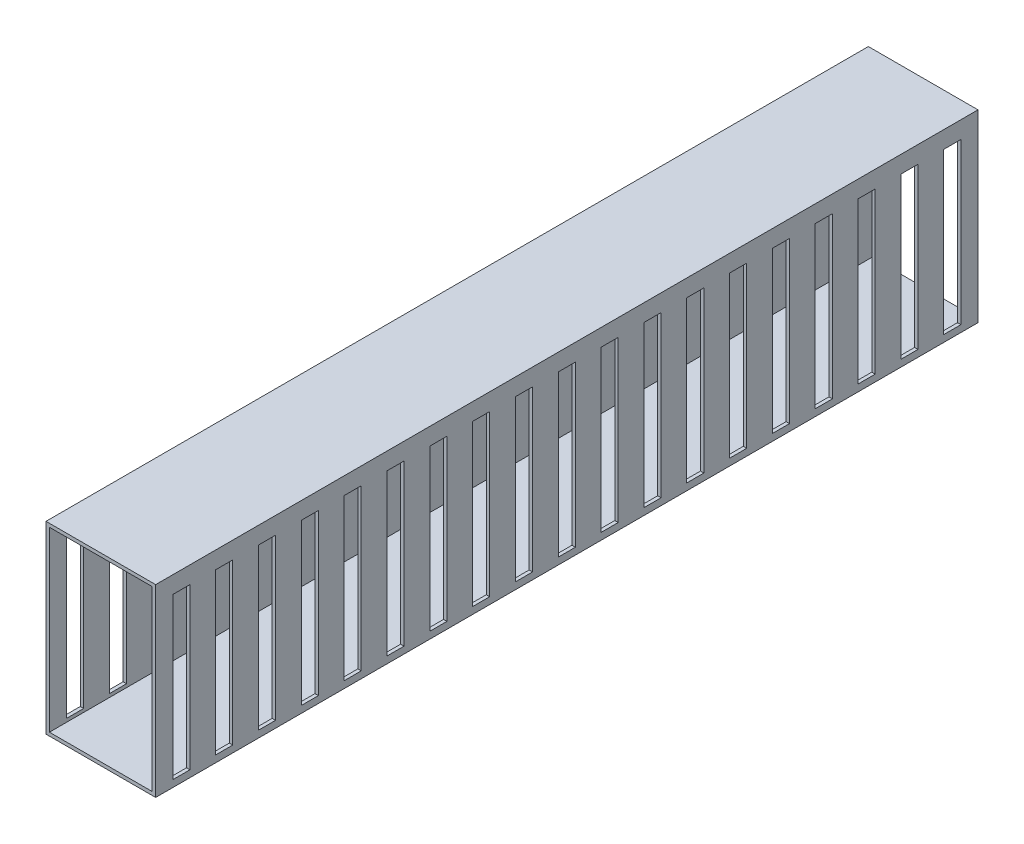
from build123d import *

# Parameters (mm, degrees)
ESQUISSE1_W                = 32
ESQUISSE1_H                = 53.8
ESQUISSE1_W_2              = 30
ESQUISSE1_H_2              = 51.8
BOSS_EXTRU_1_DEPTH         = 240
ESQUISSE2_W                = 5
ESQUISSE2_H                = 46.8
ENL_V_MAT_EXTRU_1_DEPTH    = 32
R_P_TITION_LIN_AIRE1_COUNT = 19
R_P_TITION_LIN_AIRE1_PITCH = 12.5


with BuildPart() as part:
    # Esquisse1 → Boss.-Extru.1 (new body)
    with BuildSketch(Plane.XY):
        with Locations((2.977116986, 10.236099585)):
            Rectangle(ESQUISSE1_W, ESQUISSE1_H)
        with Locations((2.977116986, 10.236099585)):
            Rectangle(ESQUISSE1_W_2, ESQUISSE1_H_2, mode=Mode.SUBTRACT)
    extrude(amount=BOSS_EXTRU_1_DEPTH)

    # Esquisse2 → Enlèv. mat.-Extru.1 (cut)
    with BuildSketch(Plane(origin=(18.977116986, 0, 0), x_dir=(0, 0, -1), z_dir=(1, 0, 0))):
        with Locations((-7.5, 8.736099585)):
            Rectangle(ESQUISSE2_W, ESQUISSE2_H)
    enl_v_mat_extru_1 = extrude(amount=-ENL_V_MAT_EXTRU_1_DEPTH, mode=Mode.SUBTRACT)

    # Répétition linéaire1: Enlèv. mat.-Extru.1 ×19
    with Locations(*[(0, 0, i * R_P_TITION_LIN_AIRE1_PITCH) for i in range(1, R_P_TITION_LIN_AIRE1_COUNT)]):
        add(enl_v_mat_extru_1, mode=Mode.SUBTRACT)


solid = part.part
